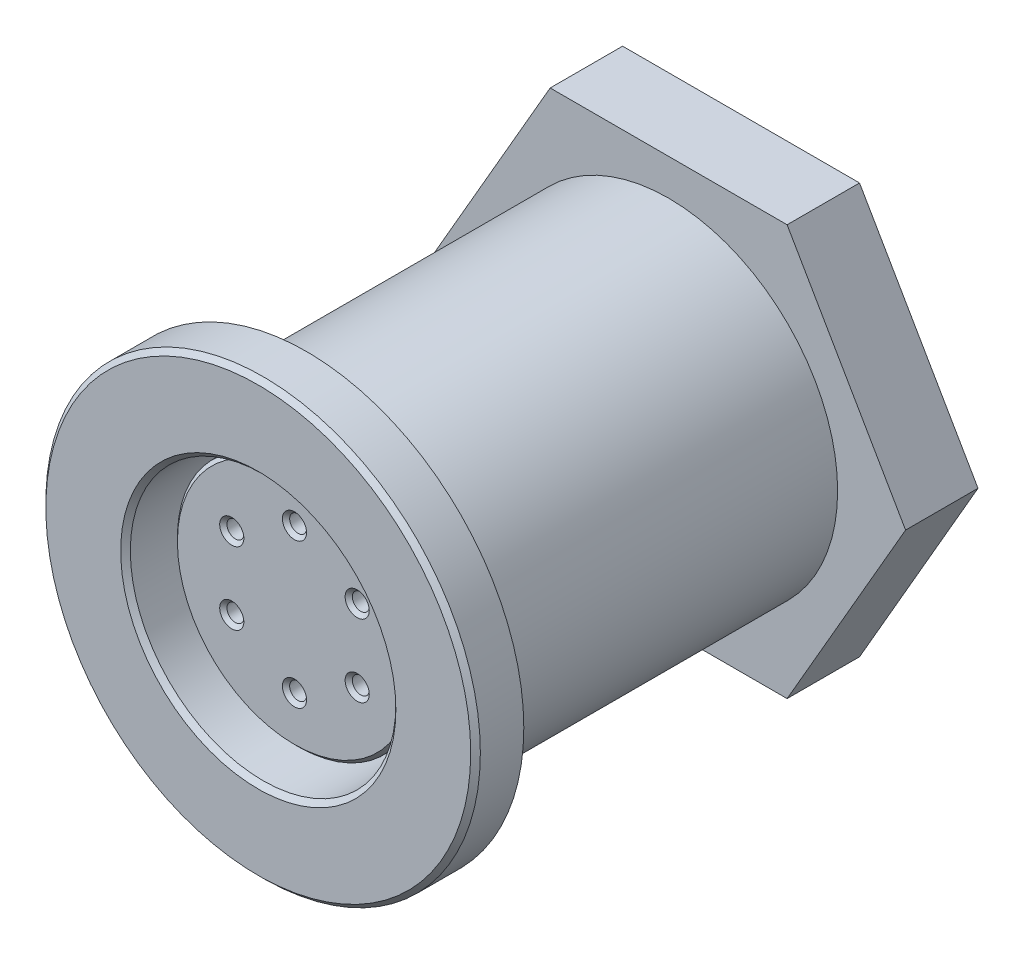
from build123d import *

# Parameters (mm, degrees)
SKETCH1_R          = 9
EXTRUDE1_DEPTH     = 2
SKETCH4_R          = 7
EXTRUDE2_DEPTH     = 19
SKETCH2_R          = 5.5
CUT_EXTRUDE1_DEPTH = 10
SKETCH3_R          = 7.8
SKETCH3_R_2        = 7
CUT_EXTRUDE2_DEPTH = 1
SKETCH5_R          = 5
EXTRUDE3_DEPTH     = 8.5
SKETCH6_R          = 0.35
CUT_EXTRUDE3_DEPTH = 7
CHAMFER2_SIZE      = 0.15
CHAMFER1_SIZE      = 0.2
SKETCH7_R          = 5
CUT_EXTRUDE4_DEPTH = 1
CHAMFER3_SIZE      = 0.5
EXTRUDE4_DEPTH     = 3


with BuildPart() as part:
    # Sketch1 → Extrude1 (new body)
    with BuildSketch(Plane.XY):
        Circle(SKETCH1_R)
    extrude(amount=EXTRUDE1_DEPTH)

    # Sketch4 → Extrude2 (add)
    with BuildSketch(Plane(origin=(0, 0, 0), x_dir=(-1, 0, 0), z_dir=(0, 0, -1))):
        Circle(SKETCH4_R)
    extrude(amount=EXTRUDE2_DEPTH)

    # Sketch2 → Cut-Extrude1 (cut)
    with BuildSketch(Plane.XY.offset(2)):
        Circle(SKETCH2_R)
    extrude(amount=-CUT_EXTRUDE1_DEPTH, mode=Mode.SUBTRACT)

    # Sketch3 → Cut-Extrude2 (cut)
    with BuildSketch(Plane(origin=(0, 0, 0), x_dir=(-1, 0, 0), z_dir=(0, 0, -1))):
        Circle(SKETCH3_R)
        Circle(SKETCH3_R_2, mode=Mode.SUBTRACT)
    extrude(amount=-CUT_EXTRUDE2_DEPTH, mode=Mode.SUBTRACT)

    # Sketch5 → Extrude3 (add)
    with BuildSketch(Plane.XY.offset(-8)):
        Circle(SKETCH5_R)
    extrude(amount=EXTRUDE3_DEPTH)

    # Sketch6 → Cut-Extrude3 (cut)
    with BuildSketch(Plane.XY.offset(0.5)):
        with Locations((0, 3)):
            Circle(SKETCH6_R)
        with Locations((0, -3)):
            Circle(SKETCH6_R)
        with Locations((2.598076211, 1.5)):
            Circle(SKETCH6_R)
        with Locations((2.598076211, -1.5)):
            Circle(SKETCH6_R)
        with Locations((-2.598076211, 1.5)):
            Circle(SKETCH6_R)
        with Locations((-2.598076211, -1.5)):
            Circle(SKETCH6_R)
    extrude(amount=-CUT_EXTRUDE3_DEPTH, mode=Mode.SUBTRACT)

    # Chamfer2
    chamfer2_edges = [part.edges().sort_by_distance(p)[0] for p in [
        (-5, 0, 0.5),
        (-0.35, 3, 0.5),
        (-0.35, -3, 0.5),
        (2.248076211, 1.5, 0.5),
        (2.248076211, -1.5, 0.5),
        (-2.948076211, 1.5, 0.5),
        (-2.948076211, -1.5, 0.5),
    ]]
    chamfer(chamfer2_edges, length=CHAMFER2_SIZE)

    # Chamfer1
    chamfer1_edges = [part.edges().sort_by_distance(p)[0] for p in [
        (-5.5, 0, 2),
        (-9, 0, 2),
    ]]
    chamfer(chamfer1_edges, length=CHAMFER1_SIZE)

    # Sketch7 → Cut-Extrude4 (cut)
    with BuildSketch(Plane(origin=(0, 0, -19), x_dir=(-1, 0, 0), z_dir=(0, 0, -1))):
        Circle(SKETCH7_R)
    extrude(amount=-CUT_EXTRUDE4_DEPTH, mode=Mode.SUBTRACT)

    # Chamfer3
    chamfer3_edges = [part.edges().sort_by_distance(p)[0] for p in [
        (7, 0, -19),
    ]]
    chamfer(chamfer3_edges, length=CHAMFER3_SIZE)

    # Sketch8 → Extrude4 (add)
    with BuildSketch(Plane(origin=(0, 0, -18), x_dir=(-1, 0, 0), z_dir=(0, 0, -1))):
        Polygon((-4.907477288, 8.5), (4.907477288, 8.5), (9.814954576, 0), (4.907477288, -8.5), (-4.907477288, -8.5), (-9.814954576, 0), align=None)
    extrude(amount=-EXTRUDE4_DEPTH)


solid = part.part
